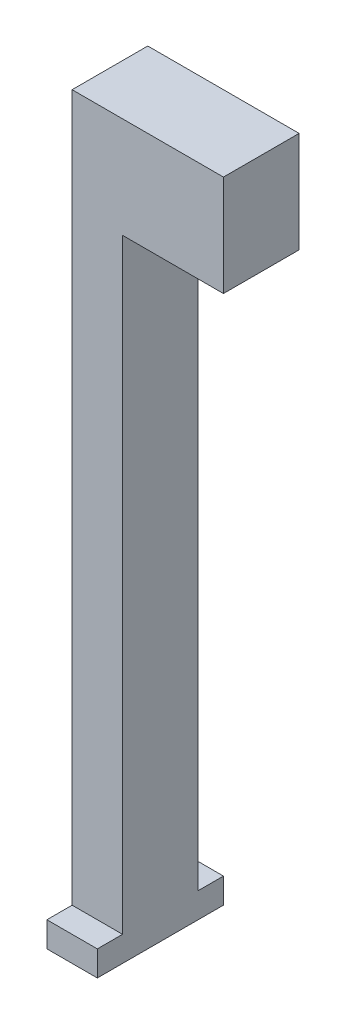
from build123d import *

# Parameters (mm, degrees)
SKETCH2_W                = 30
SKETCH2_H                = 20
SKETCH2_W_2              = 10
SKETCH2_H_2              = 120
BOSS_EXTRUDE1_DEPTH      = 15
SKETCH3_W                = 10
SKETCH3_H                = 5
BOSS_EXTRUDE2_DEPTH      = 5
BOSS_EXTRUDE2_DEPTH_BACK = 20
SKETCH5_R                = 2.517277228
CUT_EXTRUDE1_DEPTH       = 1


with BuildPart() as part:
    # Sketch2 → Boss-Extrude1 (new body)
    with BuildSketch(Plane.XY):
        Rectangle(SKETCH2_W, SKETCH2_H)
        with Locations((-10, -70)):
            Rectangle(SKETCH2_W_2, SKETCH2_H_2)
    extrude(amount=BOSS_EXTRUDE1_DEPTH)

    # Sketch3 → Boss-Extrude2 (add, two sides)
    with BuildSketch(Plane.XY.offset(15)) as boss_extrude2_sk:
        with Locations((-10, -132.5)):
            Rectangle(SKETCH3_W, SKETCH3_H)
    extrude(amount=BOSS_EXTRUDE2_DEPTH)
    extrude(boss_extrude2_sk.sketch, amount=-BOSS_EXTRUDE2_DEPTH_BACK)

    # Sketch5 → Cut-Extrude1 (cut)
    with BuildSketch(Plane.XZ.offset(10)):
        with Locations((5, 7.5)):
            Circle(SKETCH5_R)
    extrude(amount=-CUT_EXTRUDE1_DEPTH, mode=Mode.SUBTRACT)


solid = part.part
